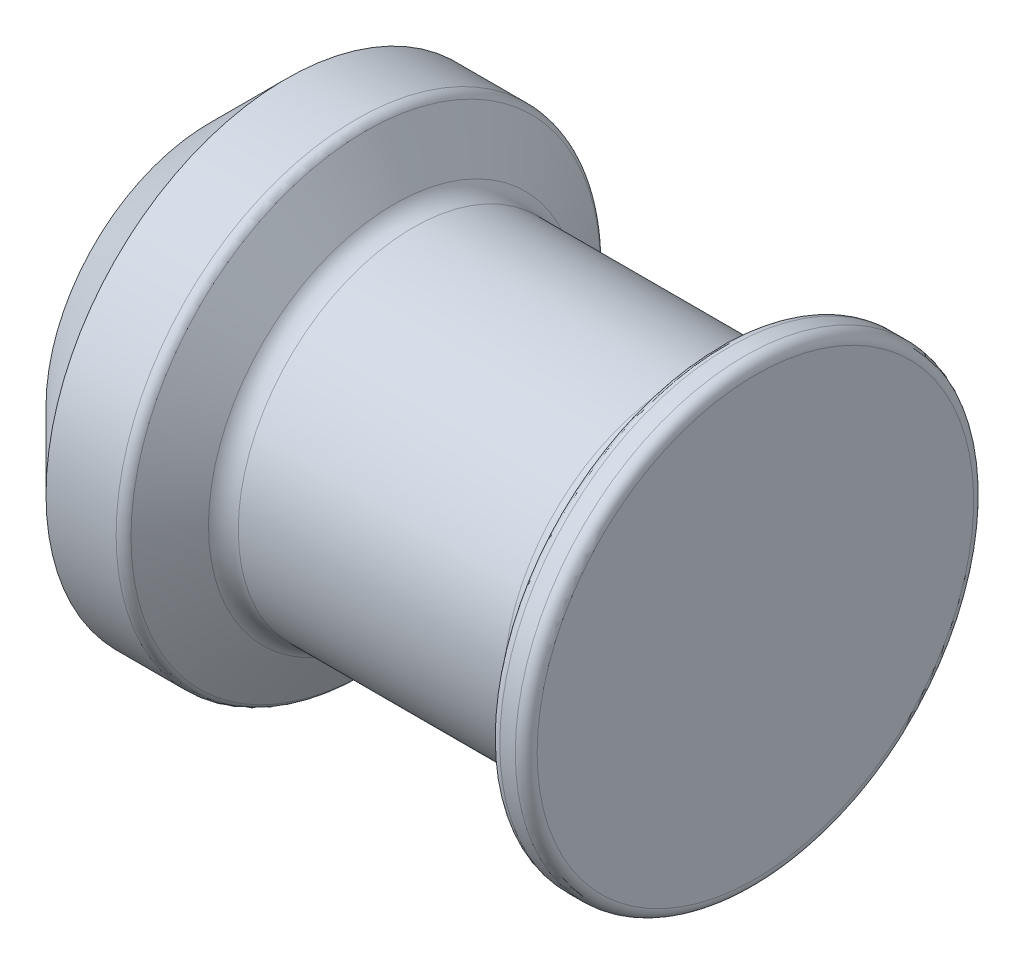
from build123d import *


with BuildPart() as part:
    # Sketch1 → Revolve1 (revolve)
    with BuildSketch(Plane.XY):
        with BuildLine():
            Line((50, 0), (50, 20))
            ThreePointArc((50, 20), (49.707106781, 20.707106781), (49, 21))
            Line((49, 21), (47.577350269, 21))
            ThreePointArc((47.577350269, 21), (47.077350269, 20.866025404), (46.711324865, 20.5))
            Line((46.711324865, 20.5), (44.690598923, 17))
            ThreePointArc((44.690598923, 17), (43.958548116, 16.267949192), (42.958548116, 16))
            Line((42.958548116, 16), (18.618802154, 16))
            ThreePointArc((18.618802154, 16), (17.618802154, 16.267949192), (16.886751346, 17))
            Line((16.886751346, 17), (14.288675135, 21.5))
            ThreePointArc((14.288675135, 21.5), (13.922649731, 21.866025404), (13.422649731, 22))
            Line((13.422649731, 22), (7, 22))
            Line((7, 22), (0, 15))
            Line((0, 15), (0, 0))
            Line((0, 0), (50, 0))
        make_face()
    revolve(axis=Axis((0, 0, 0), (1, 0, 0)))


solid = part.part
